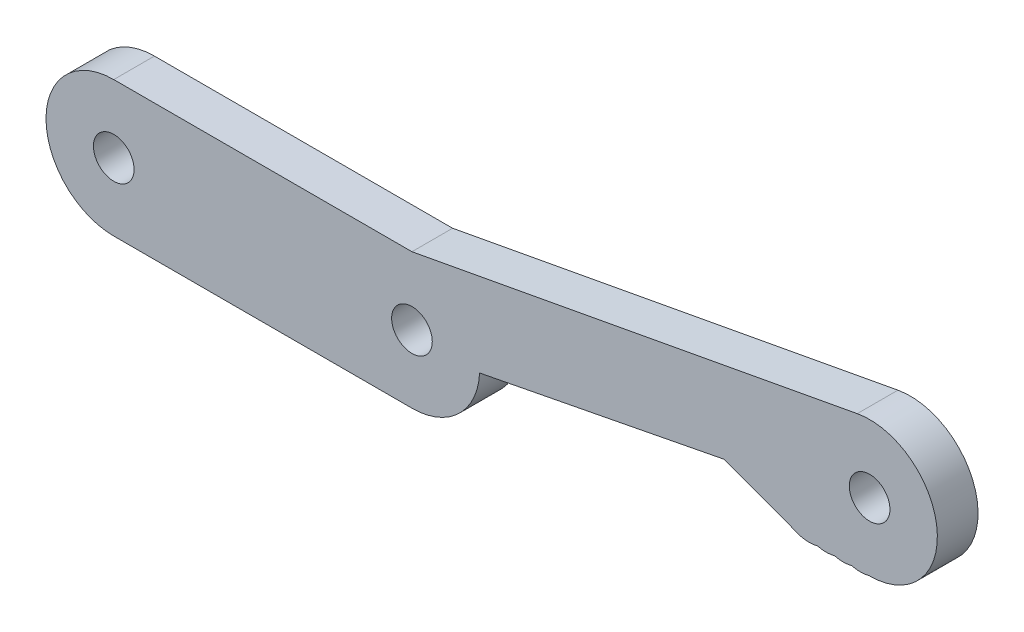
from build123d import *

# Parameters (mm, degrees)
SCHIZZO1_R                   = 1.5
ESTRUSIONE_ESTRUSIONE1_DEPTH = 3


with BuildPart() as part:
    # Schizzo1 → Estrusione-Estrusione1 (new body)
    with BuildSketch(Plane.XY):
        with BuildLine():
            Line((22, 5), (0, 5))
            ThreePointArc((0, 5), (-5, 0), (0, -5))
            Line((0, -5), (22, -5))
            ThreePointArc((22, -5), (25.445859834, -3.622989098), (26.993725045, -0.250420003))
            Line((26.993725045, -0.250420003), (45.041832618, 3.254653548))
            Line((45.041832618, 3.254653548), (50.666477461, 1.165785339))
            ThreePointArc((50.666477461, 1.165785339), (51.293977461, 1.08172232), (51.921477461, 1.165785339))
            ThreePointArc((51.921477461, 1.165785339), (52.551477461, 1.081007878), (53.181477461, 1.165785339))
            ThreePointArc((53.181477461, 1.165785339), (53.811477461, 1.081063133), (54.441477461, 1.165785339))
            ThreePointArc((54.441477461, 1.165785339), (55.071477461, 1.081063133), (55.701477461, 1.165785339))
            Line((55.701477461, 1.165785339), (55.766477461, 1.165785339))
            ThreePointArc((55.766477461, 1.165785339), (60.745551277, 6.622757917), (54.856357382, 11.082255764))
            Line((54.856357382, 11.082255764), (22, 5))
        make_face()
        Circle(SCHIZZO1_R, mode=Mode.SUBTRACT)
        with Locations((22, 0)):
            Circle(SCHIZZO1_R, mode=Mode.SUBTRACT)
        with Locations((55.766477461, 6.165785339)):
            Circle(SCHIZZO1_R, mode=Mode.SUBTRACT)
    extrude(amount=ESTRUSIONE_ESTRUSIONE1_DEPTH)


solid = part.part
